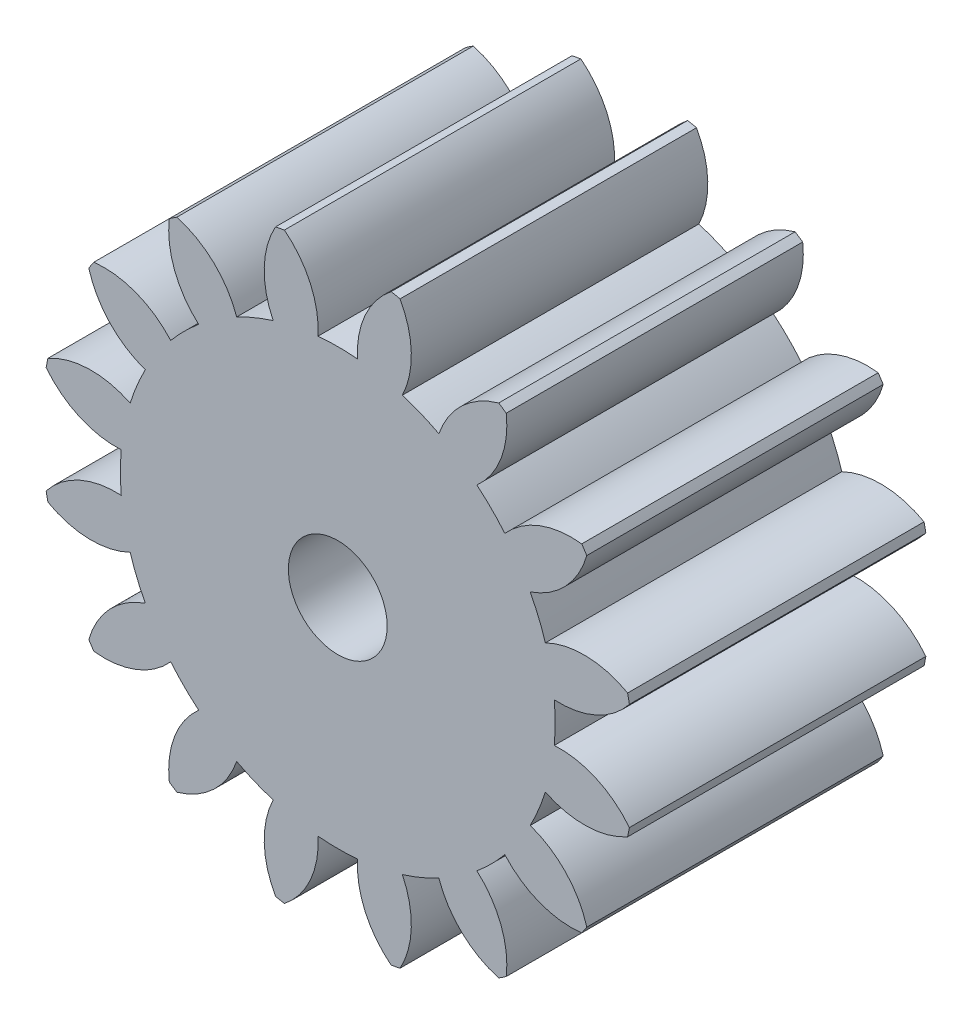
from build123d import *

# Parameters (mm, degrees)
SKETCH1_R           = 15
BOSS_EXTRUDE1_DEPTH = 15
CUT_EXTRUDE1_DEPTH  = 16
CIRPATTERN1_COUNT   = 16
SKETCH3_R           = 2.5
CUT_EXTRUDE2_DEPTH  = 16


with BuildPart() as part:
    # Sketch1 → Boss-Extrude1 (new body)
    with BuildSketch(Plane.XY):
        Circle(SKETCH1_R)
    extrude(amount=BOSS_EXTRUDE1_DEPTH)

    # Sketch2 → Cut-Extrude1 (cut, through all)
    with BuildSketch(Plane.XY.offset(15)):
        with BuildLine():
            ThreePointArc((-1, 10.95445115), (0, 11), (1, 10.95445115))
            ThreePointArc((1, 10.95445115), (1.384034944, 13.063153145), (2.7, 14.754999153))
            ThreePointArc((2.7, 14.754999153), (0, 15), (-2.7, 14.754999153))
            ThreePointArc((-2.7, 14.754999153), (-1.384034944, 13.063153145), (-1, 10.95445115))
        make_face()
    cut_extrude1 = extrude(amount=-CUT_EXTRUDE1_DEPTH, mode=Mode.SUBTRACT)

    # CirPattern1: Cut-Extrude1 ×16 about axis
    cirpattern1_axis = Axis((0, 0, 0), (0, 0, 1))
    for i in range(1, CIRPATTERN1_COUNT):
        add(cut_extrude1.rotate(cirpattern1_axis, i * 360 / CIRPATTERN1_COUNT), mode=Mode.SUBTRACT)

    # Sketch3 → Cut-Extrude2 (cut, through all)
    with BuildSketch(Plane.XY.offset(15)):
        Circle(SKETCH3_R)
    extrude(amount=-CUT_EXTRUDE2_DEPTH, mode=Mode.SUBTRACT)


solid = part.part
